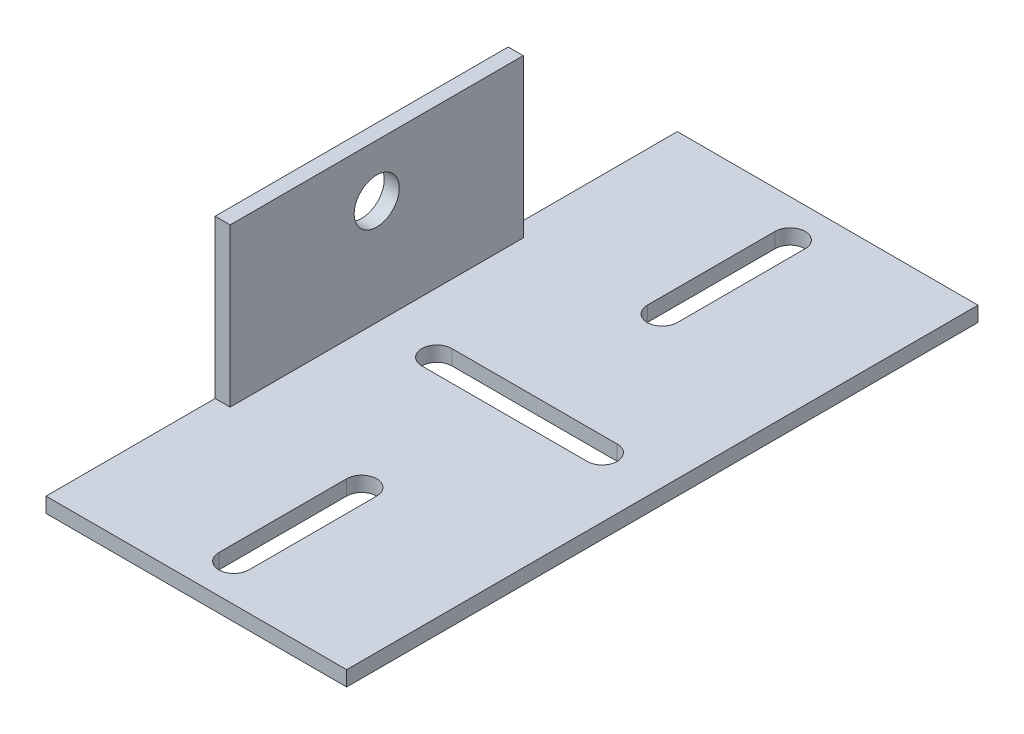
from build123d import *

# Parameters (mm, degrees)
EXTRUDE_1_DEPTH     = 84
CUT_EXTRUDE_1_DEPTH = 10
SKETCH_4_R          = 3
CUT_EXTRUDE_2_DEPTH = 10
SKETCH_5_W          = 22.5
SKETCH_5_H          = 21
CUT_EXTRUDE_3_DEPTH = 10


with BuildPart() as part:
    # Эскиз2 → Вытянуть-Тонкостенный1 (new body)
    with BuildSketch(Plane.XY):
        Polygon((0, 23), (0, 0), (40, 0), (40, 2), (2, 2), (2, 23), align=None)
    extrude(amount=EXTRUDE_1_DEPTH)

    # Эскиз3 → Вырез-Вытянуть1 (cut)
    with BuildSketch(Plane(origin=(0, 2, 0), x_dir=(1, 0, 0), z_dir=(0, 1, 0))):
        with BuildLine():
            Line((32, -40), (10, -40))
            ThreePointArc((10, -40), (8, -42), (10, -44))
            Line((10, -44), (32, -44))
            ThreePointArc((32, -44), (34, -42), (32, -40))
        make_face()
        with BuildLine():
            Line((18, -5), (18, -22))
            ThreePointArc((18, -22), (20, -24), (22, -22))
            Line((22, -22), (22, -5))
            ThreePointArc((22, -5), (20, -3), (18, -5))
        make_face()
        with BuildLine():
            Line((22, -79), (22, -62))
            ThreePointArc((22, -62), (20, -60), (18, -62))
            Line((18, -62), (18, -79))
            ThreePointArc((18, -79), (20, -81), (22, -79))
        make_face()
    extrude(amount=-CUT_EXTRUDE_1_DEPTH, mode=Mode.SUBTRACT)

    # Эскиз4 → Вырез-Вытянуть2 (cut)
    with BuildSketch(Plane.ZY):
        with Locations((42, 16)):
            Circle(SKETCH_4_R)
    extrude(amount=-CUT_EXTRUDE_2_DEPTH, mode=Mode.SUBTRACT)

    # Эскиз5 → Вырез-Вытянуть3 (cut)
    with BuildSketch(Plane.ZY):
        with Locations((11.25, 12.5)):
            Rectangle(SKETCH_5_W, SKETCH_5_H)
        with Locations((72.75, 12.5)):
            Rectangle(SKETCH_5_W, SKETCH_5_H)
    extrude(amount=-CUT_EXTRUDE_3_DEPTH, mode=Mode.SUBTRACT)


solid = part.part
